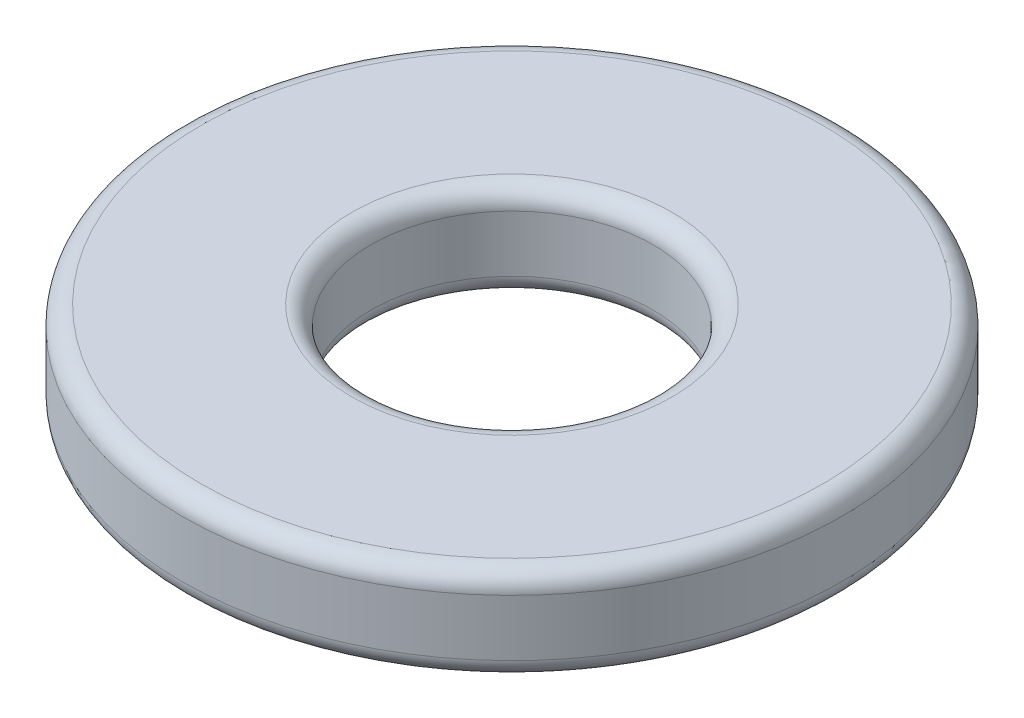
from build123d import *

# Parameters (mm, degrees)
SKETCH1_R           = 3.5
SKETCH1_R_2         = 1.5
BOSS_EXTRUDE1_DEPTH = 1
FILLET1_R           = 0.2


with BuildPart() as part:
    # Sketch1 → Boss-Extrude1 (new body)
    with BuildSketch(Plane(origin=(0, 0, 0), x_dir=(1, 0, 0), z_dir=(0, 1, 0))):
        Circle(SKETCH1_R)
        Circle(SKETCH1_R_2, mode=Mode.SUBTRACT)
    extrude(amount=BOSS_EXTRUDE1_DEPTH)

    # Fillet1
    fillet1_edges = [part.edges().sort_by_distance(p)[0] for p in [
        (-3.5, 0, 0),
        (-3.5, 1, 0),
        (-1.5, 0, 0),
        (-1.5, 1, 0),
    ]]
    fillet(fillet1_edges, radius=FILLET1_R)


solid = part.part
